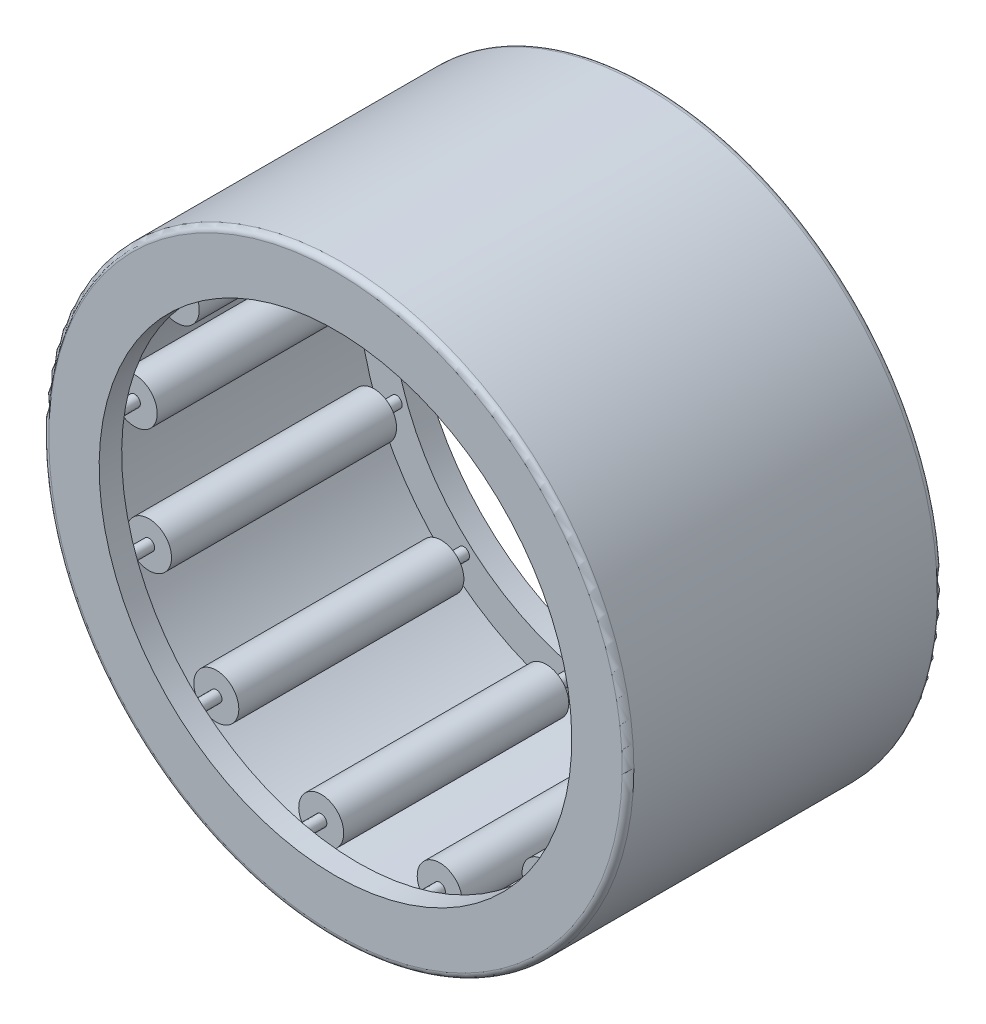
from build123d import *

# Parameters (mm, degrees)
SKETCH2_W         = 7.9375
SKETCH2_H         = 0.5953125
SKETCH3_W         = 9.525
SKETCH3_H         = 0.1984375
CIRPATTERN1_COUNT = 13
CIRPATTERN1_ANGLE = 332.307692308
FILLET1_R         = 0.206375


with BuildPart() as part:
    # Sketch1 → Revolve1 (revolve)
    with BuildSketch(Plane(origin=(0, 0, 0), x_dir=(0, 0, -1), z_dir=(1, 0, 0))):
        Polygon((-5.55625, 10.31875), (5.55625, 10.31875), (5.55625, 8.334375), (4.7625, 8.334375), (4.7625, 9.525), (-4.7625, 9.525), (-4.7625, 8.334375), (-5.55625, 8.334375), align=None)
    revolve(axis=Axis((0, 0, 5.55625), (0, 0, -1)))

    # Fillet1
    fillet1_edges = [part.edges().sort_by_distance(p)[0] for p in [
        (0, -10.31875, -5.55625),
        (0, -10.31875, 5.55625),
    ]]
    fillet(fillet1_edges, radius=FILLET1_R)


with BuildPart() as body_2:
    # Sketch2 → Revolve2 (revolve)
    with BuildSketch(Plane(origin=(0, 0, 0), x_dir=(0, 0, -1), z_dir=(1, 0, 0))):
        with Locations((0, 9.22734375)):
            Rectangle(SKETCH2_W, SKETCH2_H)
    revolve(axis=Axis((0, 8.73125, 3.96875), (0, 0, -1)))


with BuildPart() as body_3:
    # Sketch3 → Revolve3 (revolve)
    with BuildSketch(Plane(origin=(0, 0, 0), x_dir=(0, 0, -1), z_dir=(1, 0, 0))):
        with Locations((0, 8.83046875)):
            Rectangle(SKETCH3_W, SKETCH3_H)
    revolve(axis=Axis((0, 8.73125, 4.7625), (0, 0, -1)))


with BuildPart() as cirpattern1_1:
    # CirPattern1: pattern copy
    add(body_2.part.rotate(Axis((0, 0, -5.55625), (0, 0, 1)), 1 * CIRPATTERN1_ANGLE / (CIRPATTERN1_COUNT - 1)))


with BuildPart() as cirpattern1_2:
    # CirPattern1: pattern copy
    add(body_2.part.rotate(Axis((0, 0, -5.55625), (0, 0, 1)), 2 * CIRPATTERN1_ANGLE / (CIRPATTERN1_COUNT - 1)))


with BuildPart() as cirpattern1_3:
    # CirPattern1: pattern copy
    add(body_2.part.rotate(Axis((0, 0, -5.55625), (0, 0, 1)), 3 * CIRPATTERN1_ANGLE / (CIRPATTERN1_COUNT - 1)))


with BuildPart() as cirpattern1_4:
    # CirPattern1: pattern copy
    add(body_2.part.rotate(Axis((0, 0, -5.55625), (0, 0, 1)), 4 * CIRPATTERN1_ANGLE / (CIRPATTERN1_COUNT - 1)))


with BuildPart() as cirpattern1_5:
    # CirPattern1: pattern copy
    add(body_2.part.rotate(Axis((0, 0, -5.55625), (0, 0, 1)), 5 * CIRPATTERN1_ANGLE / (CIRPATTERN1_COUNT - 1)))


with BuildPart() as cirpattern1_6:
    # CirPattern1: pattern copy
    add(body_2.part.rotate(Axis((0, 0, -5.55625), (0, 0, 1)), 6 * CIRPATTERN1_ANGLE / (CIRPATTERN1_COUNT - 1)))


with BuildPart() as cirpattern1_7:
    # CirPattern1: pattern copy
    add(body_2.part.rotate(Axis((0, 0, -5.55625), (0, 0, 1)), 7 * CIRPATTERN1_ANGLE / (CIRPATTERN1_COUNT - 1)))


with BuildPart() as cirpattern1_8:
    # CirPattern1: pattern copy
    add(body_2.part.rotate(Axis((0, 0, -5.55625), (0, 0, 1)), 8 * CIRPATTERN1_ANGLE / (CIRPATTERN1_COUNT - 1)))


with BuildPart() as cirpattern1_9:
    # CirPattern1: pattern copy
    add(body_2.part.rotate(Axis((0, 0, -5.55625), (0, 0, 1)), 9 * CIRPATTERN1_ANGLE / (CIRPATTERN1_COUNT - 1)))


with BuildPart() as cirpattern1_10:
    # CirPattern1: pattern copy
    add(body_2.part.rotate(Axis((0, 0, -5.55625), (0, 0, 1)), 10 * CIRPATTERN1_ANGLE / (CIRPATTERN1_COUNT - 1)))


with BuildPart() as cirpattern1_11:
    # CirPattern1: pattern copy
    add(body_2.part.rotate(Axis((0, 0, -5.55625), (0, 0, 1)), 11 * CIRPATTERN1_ANGLE / (CIRPATTERN1_COUNT - 1)))


with BuildPart() as cirpattern1_12:
    # CirPattern1: pattern copy
    add(body_2.part.rotate(Axis((0, 0, -5.55625), (0, 0, 1)), 12 * CIRPATTERN1_ANGLE / (CIRPATTERN1_COUNT - 1)))


with BuildPart() as cirpattern1_13:
    # CirPattern1: pattern copy
    add(body_3.part.rotate(Axis((0, 0, -5.55625), (0, 0, 1)), 1 * CIRPATTERN1_ANGLE / (CIRPATTERN1_COUNT - 1)))


with BuildPart() as cirpattern1_14:
    # CirPattern1: pattern copy
    add(body_3.part.rotate(Axis((0, 0, -5.55625), (0, 0, 1)), 2 * CIRPATTERN1_ANGLE / (CIRPATTERN1_COUNT - 1)))


with BuildPart() as cirpattern1_15:
    # CirPattern1: pattern copy
    add(body_3.part.rotate(Axis((0, 0, -5.55625), (0, 0, 1)), 3 * CIRPATTERN1_ANGLE / (CIRPATTERN1_COUNT - 1)))


with BuildPart() as cirpattern1_16:
    # CirPattern1: pattern copy
    add(body_3.part.rotate(Axis((0, 0, -5.55625), (0, 0, 1)), 4 * CIRPATTERN1_ANGLE / (CIRPATTERN1_COUNT - 1)))


with BuildPart() as cirpattern1_17:
    # CirPattern1: pattern copy
    add(body_3.part.rotate(Axis((0, 0, -5.55625), (0, 0, 1)), 5 * CIRPATTERN1_ANGLE / (CIRPATTERN1_COUNT - 1)))


with BuildPart() as cirpattern1_18:
    # CirPattern1: pattern copy
    add(body_3.part.rotate(Axis((0, 0, -5.55625), (0, 0, 1)), 6 * CIRPATTERN1_ANGLE / (CIRPATTERN1_COUNT - 1)))


with BuildPart() as cirpattern1_19:
    # CirPattern1: pattern copy
    add(body_3.part.rotate(Axis((0, 0, -5.55625), (0, 0, 1)), 7 * CIRPATTERN1_ANGLE / (CIRPATTERN1_COUNT - 1)))


with BuildPart() as cirpattern1_20:
    # CirPattern1: pattern copy
    add(body_3.part.rotate(Axis((0, 0, -5.55625), (0, 0, 1)), 8 * CIRPATTERN1_ANGLE / (CIRPATTERN1_COUNT - 1)))


with BuildPart() as cirpattern1_21:
    # CirPattern1: pattern copy
    add(body_3.part.rotate(Axis((0, 0, -5.55625), (0, 0, 1)), 9 * CIRPATTERN1_ANGLE / (CIRPATTERN1_COUNT - 1)))


with BuildPart() as cirpattern1_22:
    # CirPattern1: pattern copy
    add(body_3.part.rotate(Axis((0, 0, -5.55625), (0, 0, 1)), 10 * CIRPATTERN1_ANGLE / (CIRPATTERN1_COUNT - 1)))


with BuildPart() as cirpattern1_23:
    # CirPattern1: pattern copy
    add(body_3.part.rotate(Axis((0, 0, -5.55625), (0, 0, 1)), 11 * CIRPATTERN1_ANGLE / (CIRPATTERN1_COUNT - 1)))


with BuildPart() as cirpattern1_24:
    # CirPattern1: pattern copy
    add(body_3.part.rotate(Axis((0, 0, -5.55625), (0, 0, 1)), 12 * CIRPATTERN1_ANGLE / (CIRPATTERN1_COUNT - 1)))


solid = Compound([part.part, body_2.part, body_3.part, cirpattern1_1.part, cirpattern1_2.part, cirpattern1_3.part, cirpattern1_4.part, cirpattern1_5.part, cirpattern1_6.part, cirpattern1_7.part, cirpattern1_8.part, cirpattern1_9.part, cirpattern1_10.part, cirpattern1_11.part, cirpattern1_12.part, cirpattern1_13.part, cirpattern1_14.part, cirpattern1_15.part, cirpattern1_16.part, cirpattern1_17.part, cirpattern1_18.part, cirpattern1_19.part, cirpattern1_20.part, cirpattern1_21.part, cirpattern1_22.part, cirpattern1_23.part, cirpattern1_24.part])
